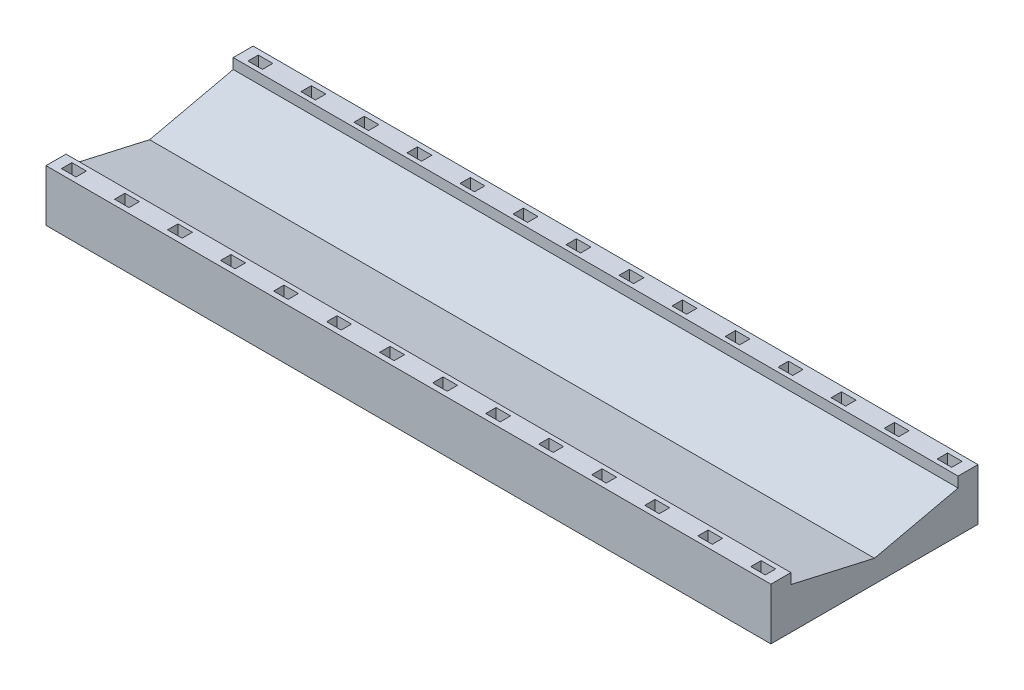
from build123d import *

# Parameters (mm, degrees)
SKETCH2_W               = 35
SKETCH2_H               = 10
BOSS_EXTRUDE1_DEPTH     = 2.5
SKETCH3_W               = 0.7
SKETCH3_H               = 0.5
CUT_EXTRUDE1_DEPTH      = 2
LPATTERN1_COUNT         = 14
LPATTERN1_PITCH         = 2.56
LPATTERN1_COUNT_DIR2    = 2
LPATTERN1_PITCH_DIR2    = 9
CUT_EXTRUDE2_DEPTH      = 1
CUT_EXTRUDE2_DEPTH_BACK = 36


with BuildPart() as part:
    # Sketch2 → Boss-Extrude1 (new body)
    with BuildSketch(Plane(origin=(0, 0, 0), x_dir=(1, 0, 0), z_dir=(0, 1, 0))):
        with Locations((17.5, 5)):
            Rectangle(SKETCH2_W, SKETCH2_H)
    extrude(amount=BOSS_EXTRUDE1_DEPTH)

    # Sketch3 → Cut-Extrude1 (cut)
    with BuildSketch(Plane(origin=(0, 2.5, 0), x_dir=(1, 0, 0), z_dir=(0, 1, 0))):
        with Locations((0.85, 0.5)):
            Rectangle(SKETCH3_W, SKETCH3_H)
    cut_extrude1 = extrude(amount=-CUT_EXTRUDE1_DEPTH, mode=Mode.SUBTRACT)

    # LPattern1: Cut-Extrude1 14 × 2
    with Locations(*[(i * LPATTERN1_PITCH, 0, -j * LPATTERN1_PITCH_DIR2) for i in range(LPATTERN1_COUNT) for j in range(LPATTERN1_COUNT_DIR2) if (i, j) != (0, 0)]):
        add(cut_extrude1, mode=Mode.SUBTRACT)

    # Sketch4 → Cut-Extrude2 (cut, two sides)
    with BuildSketch(Plane.ZY) as cut_extrude2_sk:
        Polygon((-9.038587053, 31.255911699), (-9.038587053, 2.5), (-9.038587053, 2), (-5.001909552, 1.083533753), (-0.965232052, 2), (-0.965232052, 2.5), (-0.965232052, 31.255911699), (-0.965232052, 88.767735096), (-9.038587053, 88.767735096), align=None)
    extrude(amount=CUT_EXTRUDE2_DEPTH, mode=Mode.SUBTRACT)
    extrude(cut_extrude2_sk.sketch, amount=-CUT_EXTRUDE2_DEPTH_BACK, mode=Mode.SUBTRACT)


solid = part.part
